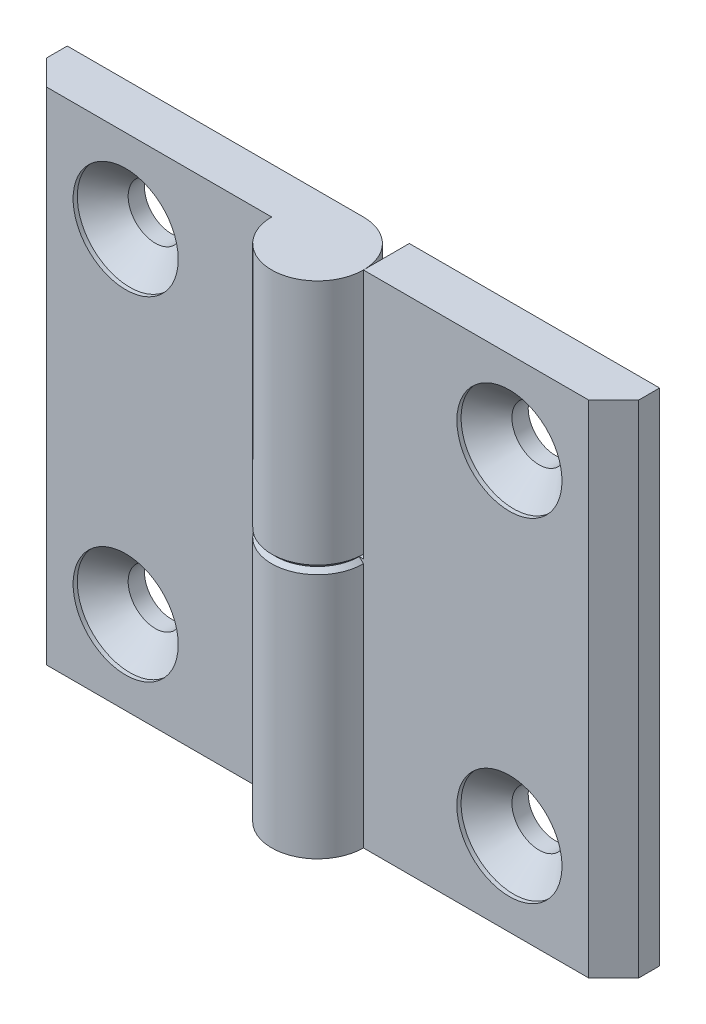
from build123d import *

# Parameters (mm, degrees)
EXTRUDE_1_DEPTH            = 30
SKETCH_3_W                 = 11
SKETCH_3_H                 = 30
CUT_EXTRUDE_1_DEPTH        = 6.5
CUT_EXTRUDE_1_DEPTH_BACK   = 6.5
HOLE_WIZARD_M61_AT_2_COUNT = 2
HOLE_WIZARD_M61_AT_2_PITCH = 40
CHAMFER_1_SIZE             = 0.5
PATTERN_CIRCULAR_1_COUNT   = 2


with BuildPart() as part:
    # Эскиз1 → Бобышка-Вытянуть1 (new body, symmetric)
    with BuildSketch(Plane(origin=(0, 0, 0), x_dir=(1, 0, 0), z_dir=(0, 1, 0))):
        with BuildLine():
            Line((0, 5.5), (-35.5, 5.5))
            Line((-35.5, 5.5), (-35.5, 3))
            Line((-35.5, 3), (-32.5, 0))
            Line((-32.5, 0), (-5.5, 0))
            ThreePointArc((-5.5, 0), (3.889087297, -3.889087297), (0, 5.5))
        make_face()
    extrude(amount=EXTRUDE_1_DEPTH, both=True)

    # Эскиз3 → Вырез-Вытянуть1 (cut, two sides)
    with BuildSketch(Plane.XY) as cut_extrude_1_sk:
        with Locations((0, -15)):
            Rectangle(SKETCH_3_W, SKETCH_3_H)
    extrude(amount=CUT_EXTRUDE_1_DEPTH, mode=Mode.SUBTRACT)
    extrude(cut_extrude_1_sk.sketch, amount=-CUT_EXTRUDE_1_DEPTH_BACK, mode=Mode.SUBTRACT)

    # Эскиз6 → Зенковка для винта с полупотайной головкой M61 (revolve, cut)
    with BuildSketch(Plane(origin=(-23, 20, 0), x_dir=(0, -1, 0), z_dir=(1, 0, 0))):
        Polygon((0, 0), (0, 5.5), (3.25, 5.5), (3.25, 3.55), (6.3, 0.5), (6.3, 0), align=None)
    hole_wizard_m61 = revolve(axis=Axis((-23, 20, 6.35), (0, 0, -1)), mode=Mode.SUBTRACT)

    # Зенковка для винта с полупотайной головкой M61 at 2: Зенковка для винта с полупотайной головкой M61 ×2
    with Locations(*[(0, -i * HOLE_WIZARD_M61_AT_2_PITCH, 0) for i in range(1, HOLE_WIZARD_M61_AT_2_COUNT)]):
        add(hole_wizard_m61, mode=Mode.SUBTRACT)

    # Фаска1
    chamfer_1_edges = [part.edges().sort_by_distance(p)[0] for p in [
        (3.889087297, 0, 3.889087297),
        (-2.75, 0, -5.5),
    ]]
    chamfer(chamfer_1_edges, length=CHAMFER_1_SIZE)


with BuildPart() as pattern_circular_1_1:
    # Круговой массив1: pattern copy
    add(part.part.rotate(Axis((0, 0, 0), (0, 0, 1)), 1 * 360 / PATTERN_CIRCULAR_1_COUNT))


solid = Compound([part.part, pattern_circular_1_1.part])
